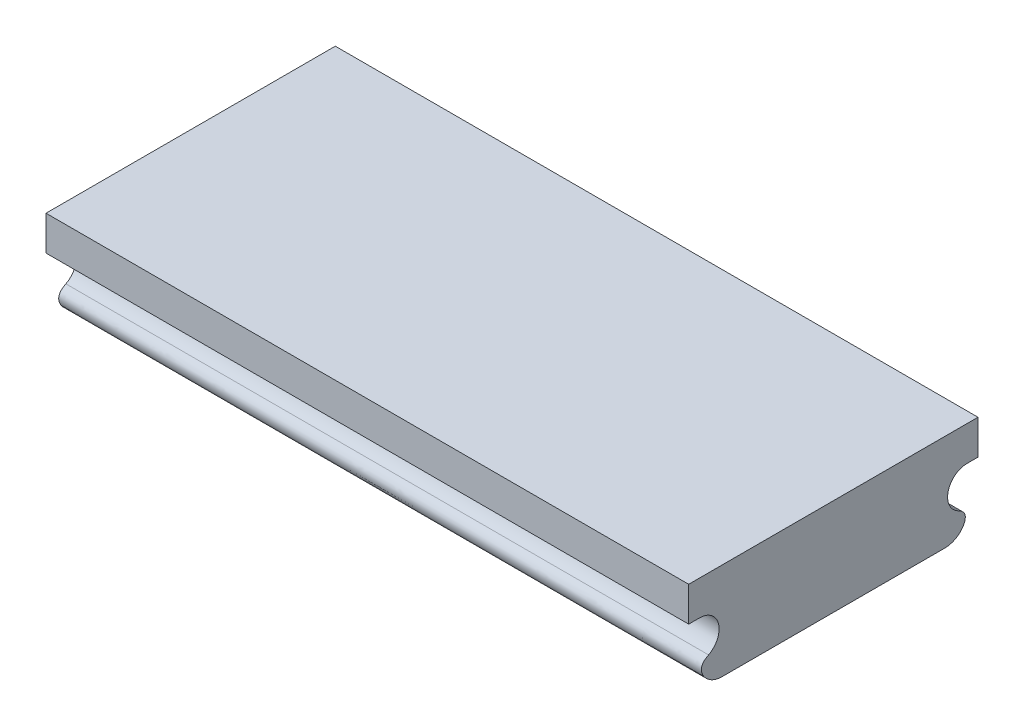
from build123d import *

# Parameters (mm, degrees)
BOSS_EXTRUDE1_DEPTH = 73.824999924


with BuildPart() as part:
    # Sketch1 → Boss-Extrude1 (new body)
    with BuildSketch(Plane(origin=(0, 0, 0), x_dir=(0, 0, -1), z_dir=(1, 0, 0))):
        with BuildLine():
            Line((-15.345833333, 15.875), (-16.615833333, 15.875))
            Line((-16.615833333, 15.875), (-16.615833333, 11.90625))
            Line((-16.615833333, 11.90625), (-15.345833333, 11.90625))
            ThreePointArc((-15.345833333, 11.90625), (-13.186497119, 10.205674607), (-14.333561104, 7.707888834))
            add(Edge.make_bspline(
                [(-14.893216846, 5.855285409), (-15.624772824, 7.07621566), (-14.333561104, 7.707888834)],
                knots=[0, 0, 0, 1, 1, 1], degree=2))
            ThreePointArc((-14.893216846, 5.855285409), (-14.258115568, 5.218639085), (-13.44097879, 4.843193137))
            ThreePointArc((-13.44097879, 4.843193137), (-13.125958752, 4.782754037), (-12.805833333, 4.7625))
            Line((-12.805833333, 4.7625), (12.805833333, 4.7625))
            ThreePointArc((12.805833333, 4.7625), (13.125958752, 4.782754037), (13.44097879, 4.843193137))
            ThreePointArc((13.44097879, 4.843193137), (14.258115568, 5.218639085), (14.893216846, 5.855285409))
            add(Edge.make_bspline(
                [(14.893216846, 5.855285409), (15.624772824, 7.07621566), (14.333561104, 7.707888834)],
                knots=[0, 0, 0, 1, 1, 1], degree=2))
            ThreePointArc((14.333561104, 7.707888834), (13.186497119, 10.205674607), (15.345833333, 11.90625))
            Line((15.345833333, 11.90625), (16.615833333, 11.90625))
            Line((16.615833333, 11.90625), (16.615833333, 15.875))
            Line((16.615833333, 15.875), (15.345833333, 15.875))
            Line((15.345833333, 15.875), (-15.345833333, 15.875))
        make_face()
    extrude(amount=BOSS_EXTRUDE1_DEPTH)


solid = part.part
